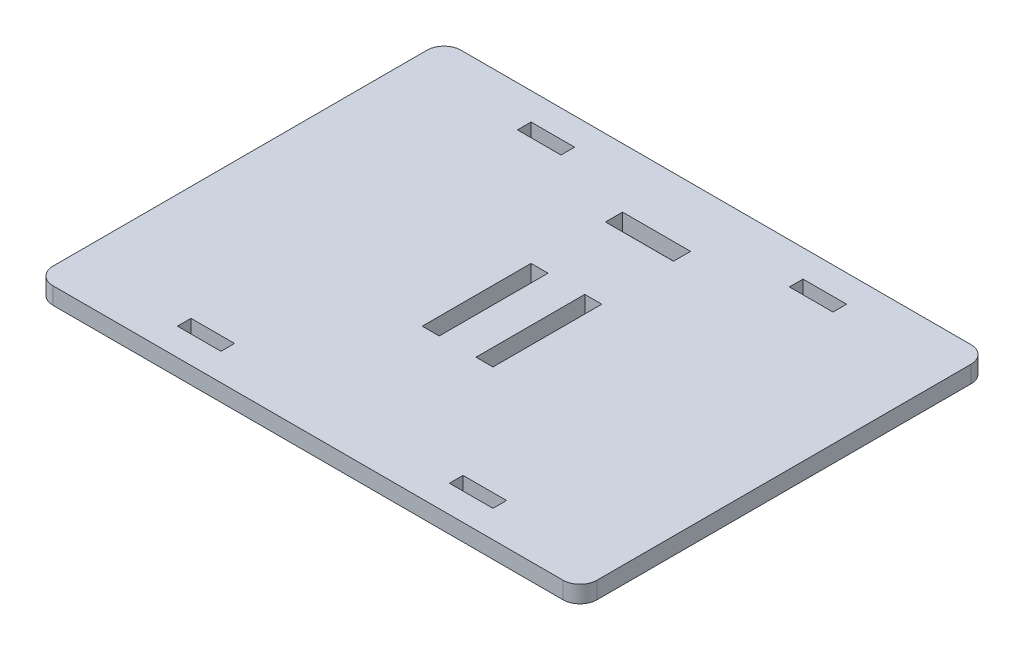
from build123d import *

# Parameters (mm, degrees)
SKETCH1_W           = 101.6
SKETCH1_H           = 76.2
SKETCH1_W_2         = 8.128
SKETCH1_H_2         = 2.54
BOSS_EXTRUDE1_DEPTH = 3.175
FILLET1_R           = 3.175
SKETCH2_W           = 3.175
SKETCH2_H           = 20.32
SKETCH2_W_2         = 12.7
SKETCH2_H_2         = 3.2004
CUT_EXTRUDE1_DEPTH  = 3.175


with BuildPart() as part:
    # Sketch1 → Boss-Extrude1 (new body)
    with BuildSketch(Plane(origin=(0, 0, 0), x_dir=(1, 0, 0), z_dir=(0, 1, 0))):
        Rectangle(SKETCH1_W, SKETCH1_H)
        with Locations((-25.4, 31.75)):
            Rectangle(SKETCH1_W_2, SKETCH1_H_2, mode=Mode.SUBTRACT)
        with Locations((-25.4, -31.75)):
            Rectangle(SKETCH1_W_2, SKETCH1_H_2, mode=Mode.SUBTRACT)
        with Locations((25.4, -31.75)):
            Rectangle(SKETCH1_W_2, SKETCH1_H_2, mode=Mode.SUBTRACT)
        with Locations((25.4, 31.75)):
            Rectangle(SKETCH1_W_2, SKETCH1_H_2, mode=Mode.SUBTRACT)
    extrude(amount=BOSS_EXTRUDE1_DEPTH)

    # Fillet1
    fillet1_edges = [part.edges().sort_by_distance(p)[0] for p in [
        (50.8, 1.5875, 38.1),
        (-50.8, 1.5875, 38.1),
        (-50.8, 1.5875, -38.1),
        (50.8, 1.5875, -38.1),
    ]]
    fillet(fillet1_edges, radius=FILLET1_R)

    # Sketch2 → Cut-Extrude1 (cut)
    with BuildSketch(Plane(origin=(0, 3.175, 0), x_dir=(1, 0, 0), z_dir=(0, 1, 0))):
        with Locations((-5.0165, 0)):
            Rectangle(SKETCH2_W, SKETCH2_H)
        with Locations((5.0165, 0)):
            Rectangle(SKETCH2_W, SKETCH2_H)
        with Locations((0, 25.4)):
            Rectangle(SKETCH2_W_2, SKETCH2_H_2)
    extrude(amount=-CUT_EXTRUDE1_DEPTH, mode=Mode.SUBTRACT)


solid = part.part
